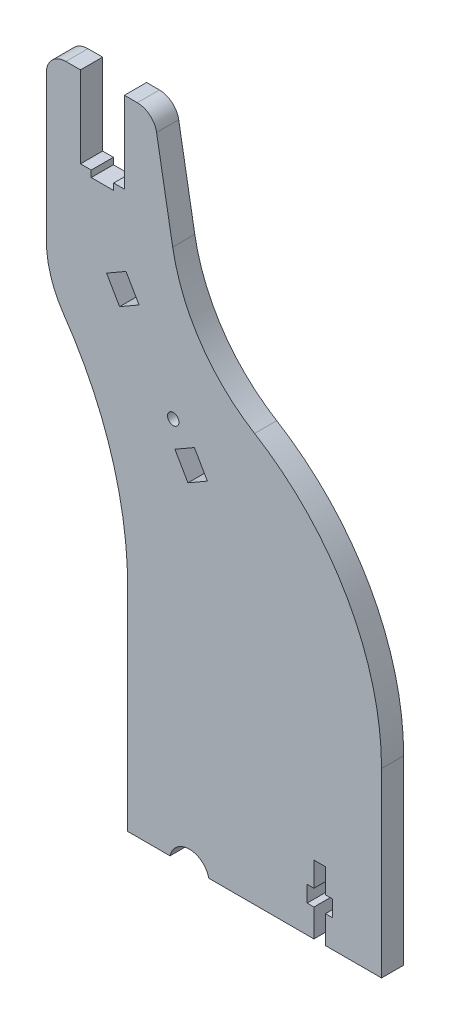
from build123d import *

# Parameters (mm, degrees)
BOSS_EXTRUDE1_DEPTH = 6.8
SKETCH2_W           = 3.55
SKETCH2_H           = 7.5
SKETCH2_W_2         = 2.085
SKETCH2_H_2         = 5
SKETCH2_H_3         = 8.5
CUT_EXTRUDE1_DEPTH  = 6.8
SKETCH3_R           = 6.1
CUT_EXTRUDE2_DEPTH  = 6.8
SKETCH4_R           = 1.75
CUT_EXTRUDE3_DEPTH  = 6.8


with BuildPart() as part:
    # Sketch1 → Boss-Extrude1 (new body)
    with BuildSketch(Plane.XY):
        with BuildLine():
            Line((-97, 195.4), (-92.5, 195.4))
            Line((-92.5, 195.4), (-92.5, 170.4))
            Line((-92.5, 170.4), (-89.2, 170.4))
            Line((-89.2, 170.4), (-89.2, 168.4))
            Line((-89.2, 168.4), (-82.3, 168.4))
            Line((-82.3, 168.4), (-82.3, 170.4))
            Line((-82.3, 170.4), (-79, 170.4))
            Line((-79, 170.4), (-79, 195.4))
            Line((-79, 195.4), (-75.034597787, 195.4))
            ThreePointArc((-75.034597787, 195.4), (-71.177872129, 193.996266659), (-69.125751269, 190.441889066))
            Line((-69.125751269, 190.441889066), (-64.181209637, 162.4))
            ThreePointArc((-64.181209637, 162.4), (-55.56310459, 141.196422986), (-39, 125.4))
            ThreePointArc((-39, 125.4), (-10.413345727, 95.649656796), (0, 55.726706578))
            Line((0, 55.726706578), (0, 0))
            Line((0, 0), (-78, 0))
            Line((-78, 0), (-78, 64.670637847))
            ThreePointArc((-78, 64.670637847), (-82.987756652, 97.72473667), (-97.652405773, 127.764697248))
            ThreePointArc((-97.652405773, 127.764697248), (-101.631906793, 135.904056195), (-103, 144.860278245))
            Line((-103, 144.860278245), (-103, 189.4))
            ThreePointArc((-103, 189.4), (-101.242640687, 193.642640687), (-97, 195.4))
        make_face()
    extrude(amount=BOSS_EXTRUDE1_DEPTH)

    # Sketch2 → Cut-Extrude1 (cut)
    with BuildSketch(Plane.XY.offset(6.8)):
        with Locations((-19, 17.25)):
            Rectangle(SKETCH2_W, SKETCH2_H)
        with Locations((-21.8175, 11)):
            Rectangle(SKETCH2_W_2, SKETCH2_H_2)
        with Locations((-16.1825, 11)):
            Rectangle(SKETCH2_W_2, SKETCH2_H_2)
        with Locations((-19, 4.25)):
            Rectangle(SKETCH2_W, SKETCH2_H_3)
        with Locations((-19, 11)):
            Rectangle(SKETCH2_W, SKETCH2_H_2)
    extrude(amount=-CUT_EXTRUDE1_DEPTH, mode=Mode.SUBTRACT)

    # Sketch3 → Cut-Extrude2 (cut)
    with BuildSketch(Plane.XY.offset(6.8)):
        with Locations((-59.04, -1.33811552)):
            Circle(SKETCH3_R)
    extrude(amount=-CUT_EXTRUDE2_DEPTH, mode=Mode.SUBTRACT)

    # Sketch4 → Cut-Extrude3 (cut)
    with BuildSketch(Plane(origin=(0, 0, 0), x_dir=(-1, 0, 0), z_dir=(0, 0, -1))):
        with Locations((64.000212357, 116.740381057)):
            Circle(SKETCH4_R)
        Polygon((84.488, 145.326270189), (78.512424714, 148.776270189), (74.512424714, 141.848066959), (80.488, 138.398066959), align=None)
        Polygon((63.488, 108.95320323), (57.512424714, 112.40320323), (53.512424714, 105.475), (59.488, 102.025), align=None)
    extrude(amount=-CUT_EXTRUDE3_DEPTH, mode=Mode.SUBTRACT)


solid = part.part
